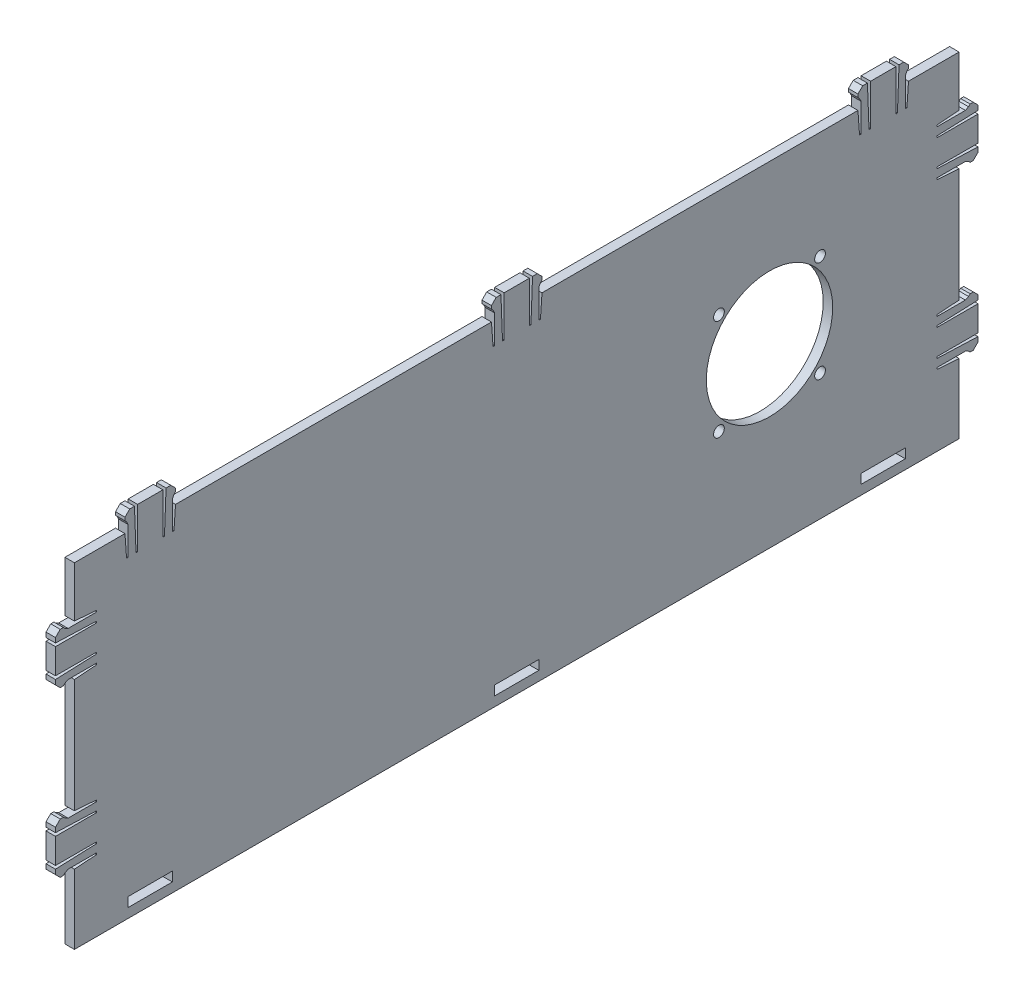
from build123d import *

# Parameters (mm, degrees)
BOSS_EXTRUDE1_DEPTH = 3
SKETCH3_W           = 14
SKETCH3_H           = 3
CUT_EXTRUDE1_DEPTH  = 3
SKETCH7_R           = 20
CUT_EXTRUDE2_DEPTH  = 3
SKETCH9_R           = 1.7
CUT_EXTRUDE3_DEPTH  = 3


with BuildPart() as part:
    # Sketch1 → Boss-Extrude1 (new body)
    with BuildSketch(Plane(origin=(0, 0, 0), x_dir=(0, 0, -1), z_dir=(1, 0, 0))):
        Polygon((-140, 34), (-140, 50), (-124, 50), (-123.5, 42.997828908), (-123, 42.997828908), (-123, 51.997828908), (-123.5, 52.997828908), (-124, 53.497828908), (-124, 54.497828908), (-122.5, 55.997828908), (-121, 55.997828908), (-120.5, 42.997828908), (-120, 42.997828908), (-120, 55.997828908), (-112, 55.997828908), (-112, 42.997828908), (-111.5, 42.997828908), (-111, 55.997828908), (-109.5, 55.997828908), (-108, 54.497828908), (-108, 53.497828908), (-108.5, 52.997828908), (-109, 51.997828908), (-109, 42.997828908), (-108.5, 42.997828908), (-108, 50), (-8, 50), (-7.5, 42.997828908), (-7, 42.997828908), (-7, 51.997828908), (-7.5, 52.997828908), (-8, 53.497828908), (-8, 54.497828908), (-6.5, 55.997828908), (-5, 55.997828908), (-4.5, 42.997828908), (-4, 42.997828908), (-4, 55.997828908), (4, 55.997828908), (4, 42.997828908), (4.5, 42.997828908), (5, 55.997828908), (6.5, 55.997828908), (8, 54.497828908), (8, 53.497828908), (7.5, 52.997828908), (7, 51.997828908), (7, 42.997828908), (7.5, 42.997828908), (8, 50), (108, 50), (108.5, 42.997828908), (109, 42.997828908), (109, 51.997828908), (108.5, 52.997828908), (108, 53.497828908), (108, 54.497828908), (109.5, 55.997828908), (111, 55.997828908), (111.5, 42.997828908), (112, 42.997828908), (112, 55.997828908), (120, 55.997828908), (120, 42.997828908), (120.5, 42.997828908), (121, 55.997828908), (122.5, 55.997828908), (124, 54.497828908), (124, 53.497828908), (123.5, 52.997828908), (123, 51.997828908), (123, 42.997828908), (123.5, 42.997828908), (124, 50), (140, 50), (140, 34), (132.997828908, 33.5), (132.997828908, 33), (141.997828908, 33), (142.997828908, 33.5), (143.497828908, 34), (144.497828908, 34), (145.997828908, 32.5), (145.997828908, 31), (132.997828908, 30.5), (132.997828908, 30), (145.997828908, 30), (145.997828908, 22), (132.997828908, 22), (132.997828908, 21.5), (145.997828908, 21), (145.997828908, 19.5), (144.497828908, 18), (143.497828908, 18), (142.997828908, 18.5), (141.997828908, 19), (132.997828908, 19), (132.997828908, 18.5), (140, 18), (140, -18), (132.997828908, -18.5), (132.997828908, -19), (141.997828908, -19), (142.997828908, -18.5), (143.497828908, -18), (144.497828908, -18), (145.997828908, -19.5), (145.997828908, -21), (132.997828908, -21.5), (132.997828908, -22), (145.997828908, -22), (145.997828908, -30), (132.997828908, -30), (132.997828908, -30.5), (145.997828908, -31), (145.997828908, -32.5), (144.497828908, -34), (143.497828908, -34), (142.997828908, -33.5), (141.997828908, -33), (132.997828908, -33), (132.997828908, -33.5), (140, -34), (140, -56), (-140, -56), (-140, -34), (-132.997828908, -33.5), (-132.997828908, -33), (-141.997828908, -33), (-142.997828908, -33.5), (-143.497828908, -34), (-144.497828908, -34), (-145.997828908, -32.5), (-145.997828908, -31), (-132.997828908, -30.5), (-132.997828908, -30), (-145.997828908, -30), (-145.997828908, -22), (-132.997828908, -22), (-132.997828908, -21.5), (-145.997828908, -21), (-145.997828908, -19.5), (-144.497828908, -18), (-143.497828908, -18), (-142.997828908, -18.5), (-141.997828908, -19), (-132.997828908, -19), (-132.997828908, -18.5), (-140, -18), (-140, 18), (-132.997828908, 18.5), (-132.997828908, 19), (-141.997828908, 19), (-142.997828908, 18.5), (-143.497828908, 18), (-144.497828908, 18), (-145.997828908, 19.5), (-145.997828908, 21), (-132.997828908, 21.5), (-132.997828908, 22), (-145.997828908, 22), (-145.997828908, 30), (-132.997828908, 30), (-132.997828908, 30.5), (-145.997828908, 31), (-145.997828908, 32.5), (-144.497828908, 34), (-143.497828908, 34), (-142.997828908, 33.5), (-141.997828908, 33), (-132.997828908, 33), (-132.997828908, 33.5), align=None)
    extrude(amount=BOSS_EXTRUDE1_DEPTH)

    # Sketch3 → Cut-Extrude1 (cut)
    with BuildSketch(Plane(origin=(3, 0, 0), x_dir=(0, 0, -1), z_dir=(1, 0, 0))):
        with Locations((-116, -51.5)):
            Rectangle(SKETCH3_W, SKETCH3_H)
        with Locations((0, -51.5)):
            Rectangle(SKETCH3_W, SKETCH3_H)
        with Locations((116, -51.5)):
            Rectangle(SKETCH3_W, SKETCH3_H)
    extrude(amount=-CUT_EXTRUDE1_DEPTH, mode=Mode.SUBTRACT)

    # Sketch7 → Cut-Extrude2 (cut)
    with BuildSketch(Plane(origin=(3, 0, 0), x_dir=(0, 0, -1), z_dir=(1, 0, 0))):
        with Locations((80, 0)):
            Circle(SKETCH7_R)
    extrude(amount=-CUT_EXTRUDE2_DEPTH, mode=Mode.SUBTRACT)

    # Sketch9 → Cut-Extrude3 (cut)
    with BuildSketch(Plane(origin=(3, 0, 0), x_dir=(0, 0, -1), z_dir=(1, 0, 0))):
        with Locations((64, 16)):
            Circle(SKETCH9_R)
        with Locations((96, 16)):
            Circle(SKETCH9_R)
        with Locations((96, -16)):
            Circle(SKETCH9_R)
        with Locations((64, -16)):
            Circle(SKETCH9_R)
    extrude(amount=-CUT_EXTRUDE3_DEPTH, mode=Mode.SUBTRACT)


solid = part.part
